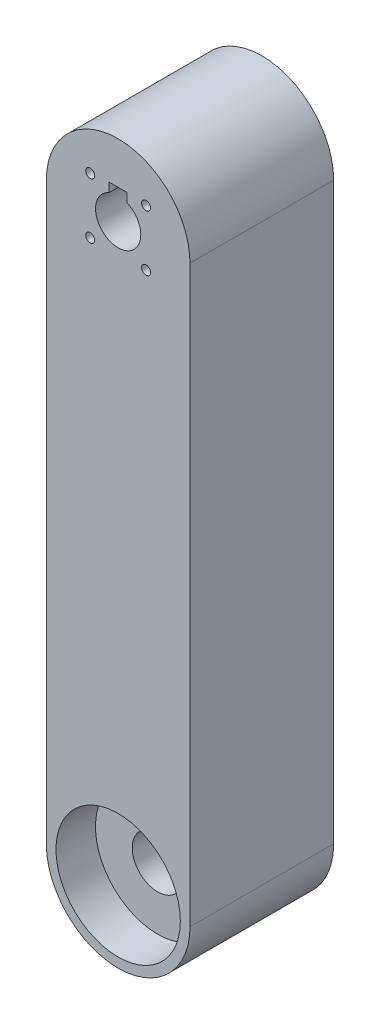
from build123d import *

# Parameters (mm, degrees)
BOSS_EXTRUDE1_DEPTH = 25.4
CUT_EXTRUDE1_REACH  = 27.4
SKETCH2_R           = 4
SKETCH2_R_2         = 0.79375
SKETCH3_W           = 3.175
SKETCH3_H           = 1.5875
CUT_EXTRUDE2_DEPTH  = 26.4
SKETCH4_R           = 10.99185
CUT_EXTRUDE3_DEPTH  = 6.985
SKETCH5_R           = 4.5
CUT_EXTRUDE4_DEPTH  = 19.415


with BuildPart() as part:
    # Sketch1 → Boss-Extrude1 (new body)
    with BuildSketch(Plane.XY):
        with BuildLine():
            Line((12.7, 50.8), (12.7, -50.8))
            ThreePointArc((12.7, -50.8), (0, -63.5), (-12.7, -50.8))
            Line((-12.7, -50.8), (-12.7, 50.8))
            ThreePointArc((-12.7, 50.8), (0, 63.5), (12.7, 50.8))
        make_face()
    extrude(amount=BOSS_EXTRUDE1_DEPTH)

    # Sketch2 → Cut-Extrude1 (cut, up to next)
    with BuildSketch(Plane.XY.offset(25.4), mode=Mode.PRIVATE) as cut_extrude1_sk1:
        with Locations((0, 50.8)):
            Circle(SKETCH2_R)
    cut_extrude1_tool1 = extrude(cut_extrude1_sk1.sketch, amount=-CUT_EXTRUDE1_REACH, mode=Mode.PRIVATE) & part.part
    add(cut_extrude1_tool1.solids().sort_by_distance((0, 50.8, 25.4))[0], mode=Mode.SUBTRACT)
    # Sketch2 → Cut-Extrude1 (cut, up to next)
    with BuildSketch(Plane.XY.offset(25.4), mode=Mode.PRIVATE) as cut_extrude1_sk2:
        with Locations((-4.939140867, 55.739140867)):
            Circle(SKETCH2_R_2)
    cut_extrude1_tool2 = extrude(cut_extrude1_sk2.sketch, amount=-CUT_EXTRUDE1_REACH, mode=Mode.PRIVATE) & part.part
    add(cut_extrude1_tool2.solids().sort_by_distance((-4.939141, 55.739141, 25.4))[0], mode=Mode.SUBTRACT)
    # Sketch2 → Cut-Extrude1 (cut, up to next)
    with BuildSketch(Plane.XY.offset(25.4), mode=Mode.PRIVATE) as cut_extrude1_sk3:
        with Locations((-4.939140867, 45.860859133)):
            Circle(SKETCH2_R_2)
    cut_extrude1_tool3 = extrude(cut_extrude1_sk3.sketch, amount=-CUT_EXTRUDE1_REACH, mode=Mode.PRIVATE) & part.part
    add(cut_extrude1_tool3.solids().sort_by_distance((-4.939141, 45.860859, 25.4))[0], mode=Mode.SUBTRACT)
    # Sketch2 → Cut-Extrude1 (cut, up to next)
    with BuildSketch(Plane.XY.offset(25.4), mode=Mode.PRIVATE) as cut_extrude1_sk4:
        with Locations((4.939140867, 55.739140867)):
            Circle(SKETCH2_R_2)
    cut_extrude1_tool4 = extrude(cut_extrude1_sk4.sketch, amount=-CUT_EXTRUDE1_REACH, mode=Mode.PRIVATE) & part.part
    add(cut_extrude1_tool4.solids().sort_by_distance((4.939141, 55.739141, 25.4))[0], mode=Mode.SUBTRACT)
    # Sketch2 → Cut-Extrude1 (cut, up to next)
    with BuildSketch(Plane.XY.offset(25.4), mode=Mode.PRIVATE) as cut_extrude1_sk5:
        with Locations((4.939140867, 45.860859133)):
            Circle(SKETCH2_R_2)
    cut_extrude1_tool5 = extrude(cut_extrude1_sk5.sketch, amount=-CUT_EXTRUDE1_REACH, mode=Mode.PRIVATE) & part.part
    add(cut_extrude1_tool5.solids().sort_by_distance((4.939141, 45.860859, 25.4))[0], mode=Mode.SUBTRACT)

    # Sketch3 → Cut-Extrude2 (cut, through all)
    with BuildSketch(Plane.XY.offset(25.4)):
        with Locations((0, 55.265240671)):
            Rectangle(SKETCH3_W, SKETCH3_H)
    extrude(amount=-CUT_EXTRUDE2_DEPTH, mode=Mode.SUBTRACT)

    # Sketch4 → Cut-Extrude3 (cut)
    with BuildSketch(Plane.XY.offset(25.4)):
        with Locations((0, -50.8)):
            Circle(SKETCH4_R)
    cut_extrude3 = extrude(amount=-CUT_EXTRUDE3_DEPTH, mode=Mode.SUBTRACT)

    # Mirror1: Cut-Extrude3 across plane
    add(cut_extrude3.mirror(Plane.XY.offset(12.7)), mode=Mode.SUBTRACT)

    # Sketch5 → Cut-Extrude4 (cut, through all)
    with BuildSketch(Plane.XY.offset(18.415)):
        with Locations((0, -50.8)):
            Circle(SKETCH5_R)
    extrude(amount=-CUT_EXTRUDE4_DEPTH, mode=Mode.SUBTRACT)


solid = part.part
